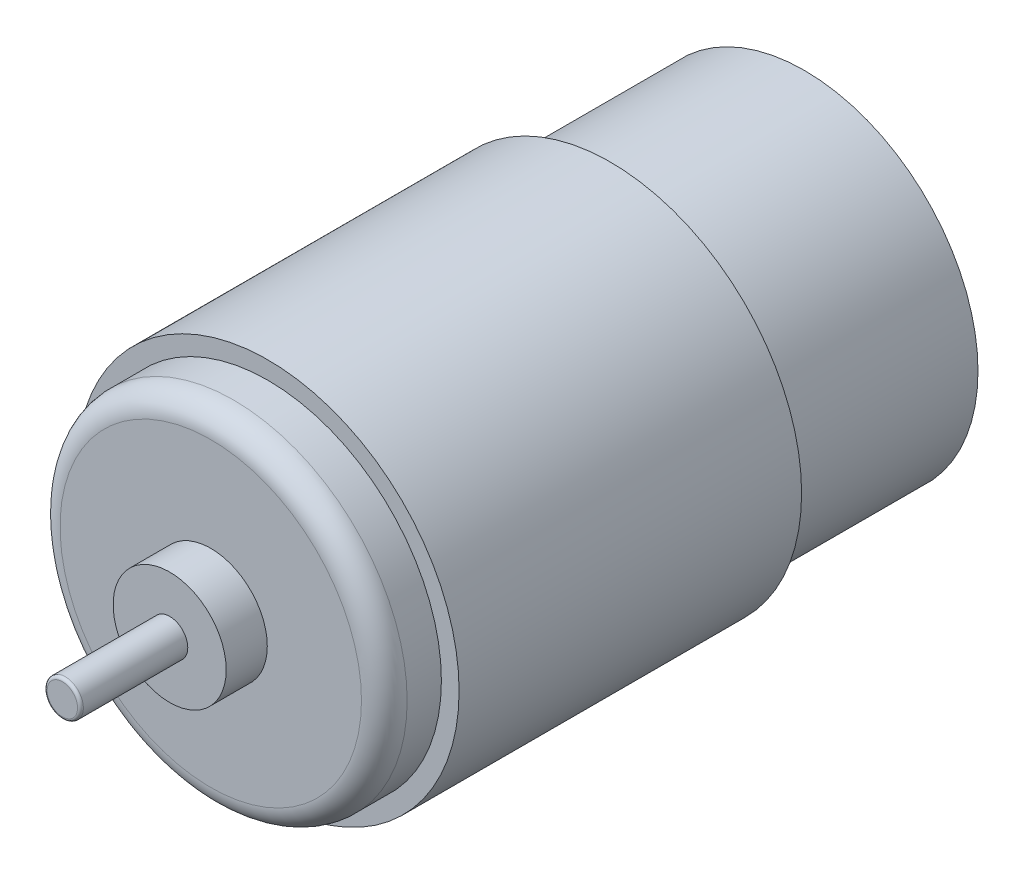
from build123d import *

# Parameters (mm, degrees)
SKETCH1_R           = 16.75
BOSS_EXTRUDE1_DEPTH = 30
SKETCH2_R           = 15.2
BOSS_EXTRUDE2_DEPTH = 5
FILLET1_R           = 2
SKETCH3_R           = 15.2
BOSS_EXTRUDE3_DEPTH = 17
SKETCH4_R           = 4.95
BOSS_EXTRUDE4_DEPTH = 3.6
SKETCH5_R           = 5
BOSS_EXTRUDE5_DEPTH = 2.6
SKETCH6_R           = 1.585
BOSS_EXTRUDE6_DEPTH = 9.4
FILLET2_R           = 0.254


with BuildPart() as part:
    # Sketch1 → Boss-Extrude1 (new body)
    with BuildSketch(Plane.XY):
        Circle(SKETCH1_R)
    extrude(amount=BOSS_EXTRUDE1_DEPTH)

    # Sketch2 → Boss-Extrude2 (add)
    with BuildSketch(Plane.XY.offset(30)):
        Circle(SKETCH2_R)
    extrude(amount=BOSS_EXTRUDE2_DEPTH)

    # Fillet1
    fillet1_edges = [part.edges().sort_by_distance(p)[0] for p in [
        (-15.2, 0, 35),
    ]]
    fillet(fillet1_edges, radius=FILLET1_R)

    # Sketch3 → Boss-Extrude3 (add)
    with BuildSketch(Plane(origin=(0, 0, 0), x_dir=(-1, 0, 0), z_dir=(0, 0, -1))):
        Circle(SKETCH3_R)
    extrude(amount=BOSS_EXTRUDE3_DEPTH)

    # Sketch4 → Boss-Extrude4 (add)
    with BuildSketch(Plane.XY.offset(35)):
        Circle(SKETCH4_R)
    extrude(amount=BOSS_EXTRUDE4_DEPTH)

    # Sketch5 → Boss-Extrude5 (add)
    with BuildSketch(Plane(origin=(0, 0, -17), x_dir=(-1, 0, 0), z_dir=(0, 0, -1))):
        Circle(SKETCH5_R)
    extrude(amount=BOSS_EXTRUDE5_DEPTH)

    # Sketch6 → Boss-Extrude6 (add)
    with BuildSketch(Plane.XY.offset(38.6)):
        Circle(SKETCH6_R)
    extrude(amount=BOSS_EXTRUDE6_DEPTH)

    # Fillet2
    fillet2_edges = [part.edges().sort_by_distance(p)[0] for p in [
        (-1.585, 0, 48),
    ]]
    fillet(fillet2_edges, radius=FILLET2_R)


solid = part.part
